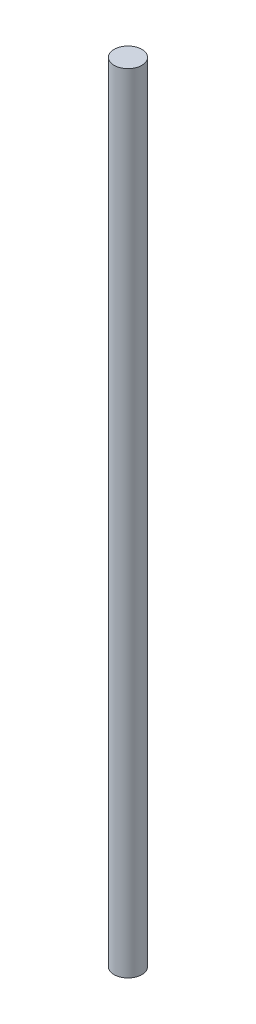
from build123d import *

# Parameters (mm, degrees)
CROQUIS1_R              = 2.5
SALIENTE_EXTRUIR1_DEPTH = 142


with BuildPart() as part:
    # Croquis1 → Saliente-Extruir1 (new body)
    with BuildSketch(Plane(origin=(0, 0, 0), x_dir=(1, 0, 0), z_dir=(0, 1, 0))):
        Circle(CROQUIS1_R)
    extrude(amount=SALIENTE_EXTRUIR1_DEPTH)


solid = part.part
